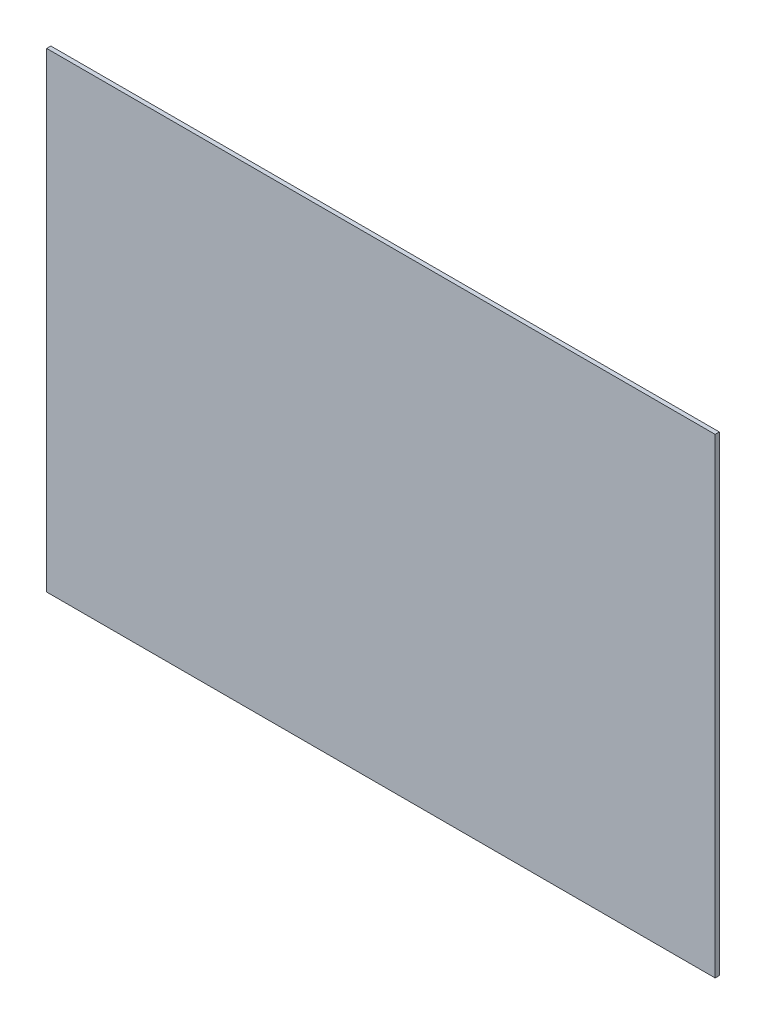
from build123d import *

# Parameters (mm, degrees)
SKETCH1_W           = 4.0524
SKETCH1_H           = 2.854
BOSS_EXTRUDE1_DEPTH = 0.0254


with BuildPart() as part:
    # Sketch1 → Boss-Extrude1 (new body)
    with BuildSketch(Plane.XY):
        Rectangle(SKETCH1_W, SKETCH1_H)
    extrude(amount=BOSS_EXTRUDE1_DEPTH)


solid = part.part
